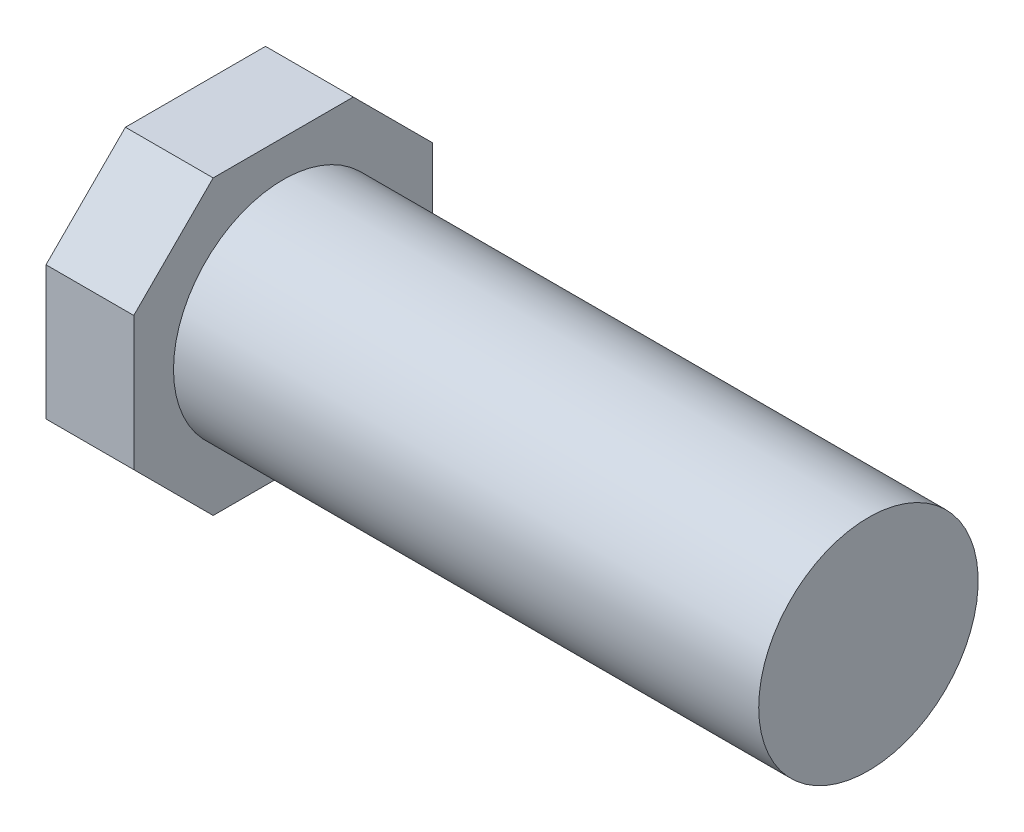
from build123d import *

# Parameters (mm, degrees)
SKETCH1_R                = 3.75
BOSS_EXTRUDE1_DEPTH      = 14
BOSS_EXTRUDE1_DEPTH_BACK = 9
BOSS_EXTRUDE2_DEPTH      = 3


with BuildPart() as part:
    # Sketch1 → Boss-Extrude1 (new body, two sides)
    with BuildSketch(Plane.ZY.offset(-65.969208633)) as boss_extrude1_sk:
        with Locations((-5.344766421, 7.785620452)):
            Circle(SKETCH1_R)
    extrude(amount=BOSS_EXTRUDE1_DEPTH)
    extrude(boss_extrude1_sk.sketch, amount=-BOSS_EXTRUDE1_DEPTH_BACK)

    # Sketch2 → Boss-Extrude2 (add)
    with BuildSketch(Plane.ZY.offset(-51.969208633)):
        Polygon((-9.094766421, 11.42591126), (-7.738890169, 12.781787511), (-2.950642672, 12.781787511), (-1.594766421, 11.42591126), (-0.237121401, 10.06826624), (-0.237121401, 5.502974665), (-1.594766421, 4.145329645), (-2.950642672, 2.789453394), (-7.738890169, 2.789453394), (-9.094766421, 4.145329645), (-10.45241144, 5.502974665), (-10.45241144, 10.06826624), align=None)
    extrude(amount=-BOSS_EXTRUDE2_DEPTH)


solid = part.part
